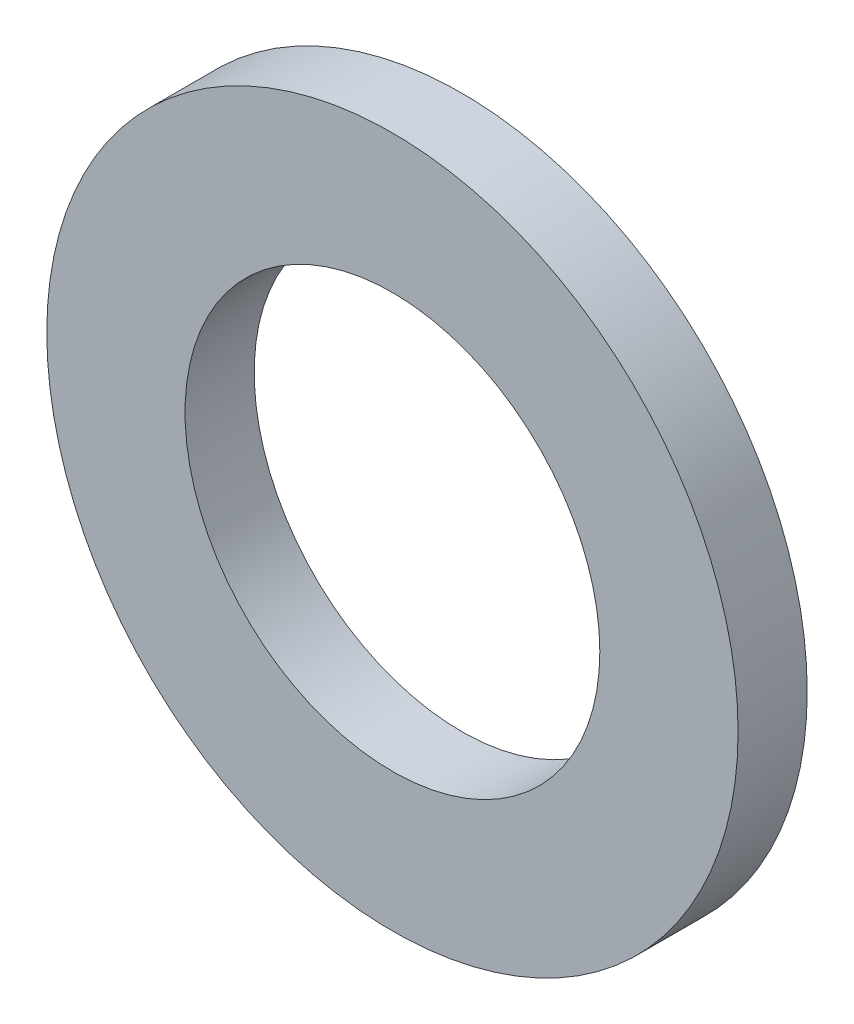
from build123d import *

# Parameters (mm, degrees)
SKETCH_1_R      = 2.5
SKETCH_1_R_2    = 1.5
EXTRUDE_1_DEPTH = 0.25


with BuildPart() as part:
    # 草图1 → 凸台-拉伸1 (new body, symmetric)
    with BuildSketch(Plane.XY):
        Circle(SKETCH_1_R)
        Circle(SKETCH_1_R_2, mode=Mode.SUBTRACT)
    extrude(amount=EXTRUDE_1_DEPTH, both=True)


solid = part.part
